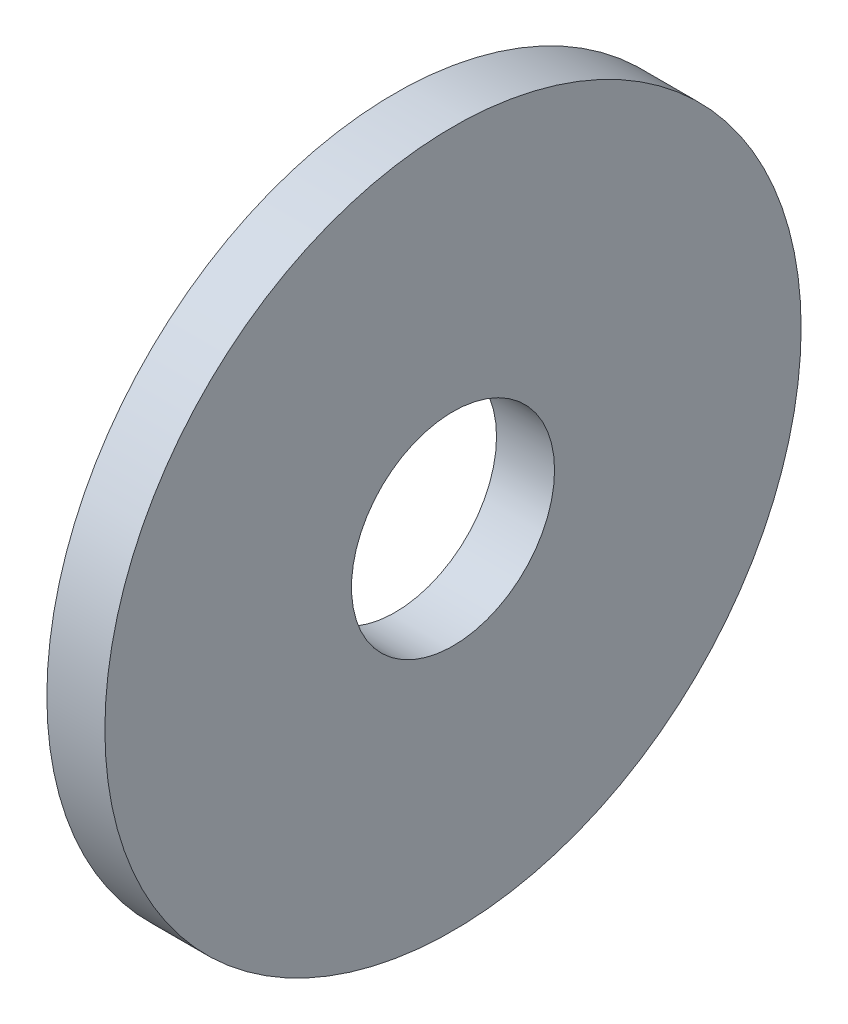
from build123d import *

# Parameters (mm, degrees)
SKETCH_1_R      = 6
SKETCH_1_R_2    = 1.75
EXTRUDE_1_DEPTH = 1


with BuildPart() as part:
    # 草图1 → 凸台-拉伸1 (new body)
    with BuildSketch(Plane(origin=(0, 0, 0), x_dir=(0, 0, -1), z_dir=(1, 0, 0))):
        Circle(SKETCH_1_R)
        Circle(SKETCH_1_R_2, mode=Mode.SUBTRACT)
    extrude(amount=EXTRUDE_1_DEPTH)


solid = part.part
